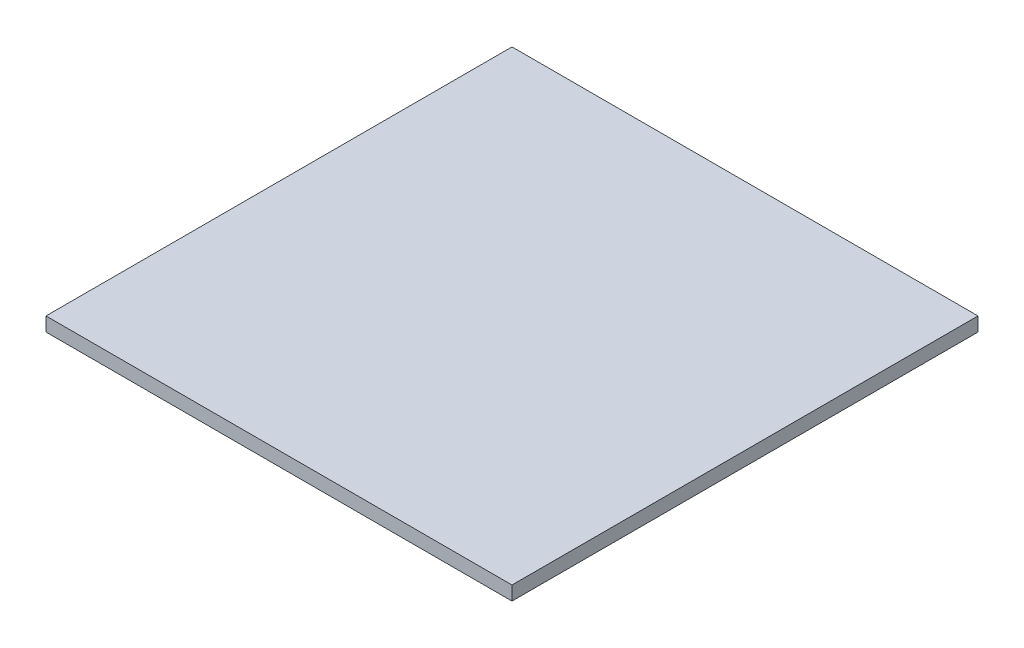
from build123d import *

# Parameters (mm, degrees)
SKETCH_1_W      = 100
SKETCH_1_H      = 100
EXTRUDE_1_DEPTH = 3


with BuildPart() as part:
    # Эскиз1 → Бобышка-Вытянуть1 (new body)
    with BuildSketch(Plane(origin=(0, 0, 0), x_dir=(1, 0, 0), z_dir=(0, 1, 0))):
        with Locations((-30.263157895, -6.25)):
            Rectangle(SKETCH_1_W, SKETCH_1_H)
    extrude(amount=EXTRUDE_1_DEPTH)


solid = part.part
